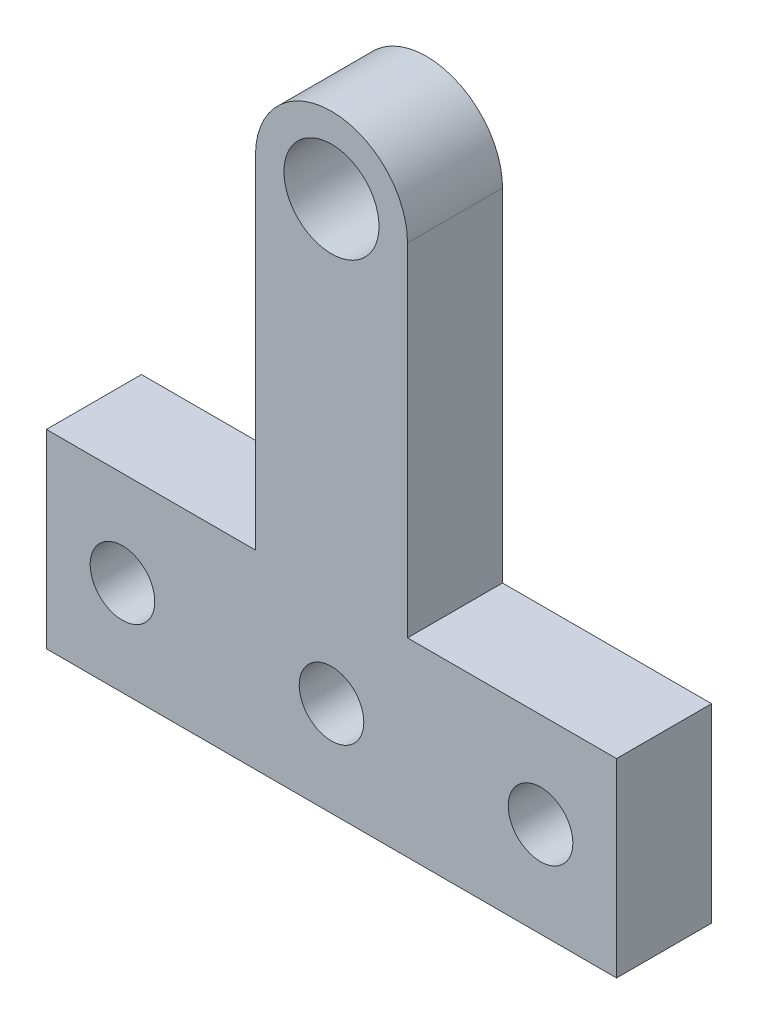
from build123d import *

# Parameters (mm, degrees)
BOSS_EXTRUDE1_DEPTH                                 = 5
SKETCH2_R                                           = 2.5
CUT_EXTRUDE1_DEPTH                                  = 6
CSK_FOR_M3_COUNTERSUNK_FLAT_HEAD_SCREW1_D           = 3.4
CSK_FOR_M3_COUNTERSUNK_FLAT_HEAD_SCREW1_DEPTH       = 5
CSK_FOR_M3_COUNTERSUNK_FLAT_HEAD_SCREW1_CSINK_D     = 6.3
CSK_FOR_M3_COUNTERSUNK_FLAT_HEAD_SCREW1_CSINK_ANGLE = 90


with BuildPart() as part:
    # Sketch1 → Boss-Extrude1 (new body)
    with BuildSketch(Plane.XY):
        with BuildLine():
            Line((4, 10), (4, 28))
            ThreePointArc((4, 28), (0, 32), (-4, 28))
            Line((-4, 28), (-4, 10))
            Line((-4, 10), (-15, 10))
            Line((-15, 10), (-15, 0))
            Line((-15, 0), (15, 0))
            Line((15, 0), (15, 10))
            Line((15, 10), (4, 10))
        make_face()
    extrude(amount=BOSS_EXTRUDE1_DEPTH)

    # Sketch2 → Cut-Extrude1 (cut, through all)
    with BuildSketch(Plane.XY.offset(5)):
        with Locations((0, 28)):
            Circle(SKETCH2_R)
    extrude(amount=-CUT_EXTRUDE1_DEPTH, mode=Mode.SUBTRACT)

    # CSK for M3 Countersunk Flat Head Screw1
    with Locations(Plane(origin=(0, 0, 0), x_dir=(-1, 0, 0), z_dir=(0, 0, -1))):
        with Locations((0, 5), (11, 5), (-11, 5)):
            CounterSinkHole(CSK_FOR_M3_COUNTERSUNK_FLAT_HEAD_SCREW1_D / 2, CSK_FOR_M3_COUNTERSUNK_FLAT_HEAD_SCREW1_CSINK_D / 2, depth=CSK_FOR_M3_COUNTERSUNK_FLAT_HEAD_SCREW1_DEPTH, counter_sink_angle=CSK_FOR_M3_COUNTERSUNK_FLAT_HEAD_SCREW1_CSINK_ANGLE)


solid = part.part
